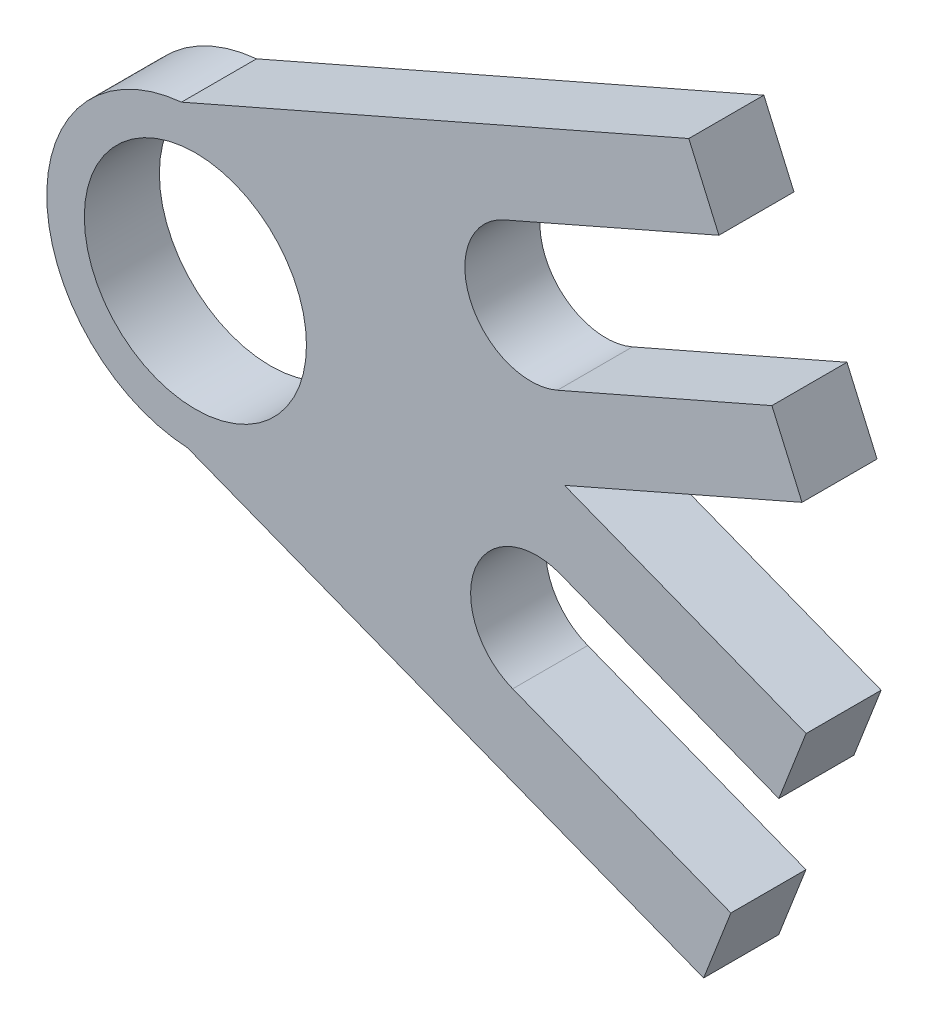
from build123d import *

# Parameters (mm, degrees)
SKETCH1_R           = 12.573
SKETCH1_R_2         = 9.398
BOSS_EXTRUDE1_DEPTH = 3.175


with BuildPart() as part:
    # Sketch1 → Boss-Extrude1 (new body, symmetric)
    with BuildSketch(Plane.XY):
        with BuildLine():
            ThreePointArc((-578.972943543, -1.57558157), (-586.333231698, 1.301508328), (-583.456141799, 8.661796483))
            Line((-583.456141799, 8.661796483), (-565.308062523, 16.6092843))
            Line((-565.308062523, 16.6092843), (-567.855334259, 22.425976375))
            Line((-567.855334259, 22.425976375), (-610.775024162, 3.630394351))
            ThreePointArc((-610.775024162, 3.630394351), (-605.901582727, 3.129161319), (-601.589679699, 0.803401606))
            Line((-601.589679699, 0.803401606), (-578.370817834, -8.244100669))
            Line((-578.370817834, -8.244100669), (-558.277592531, 0.555214171))
            Line((-558.277592531, 0.555214171), (-560.824864268, 6.371906247))
            Line((-560.824864268, 6.371906247), (-578.972943543, -1.57558157))
        make_face()
        with BuildLine():
            Line((-578.370817834, -8.244100669), (-601.589679699, 0.803401606))
            ThreePointArc((-601.589679699, 0.803401606), (-598.22471789, -3.531900701), (-597.027, -8.887578616))
            ThreePointArc((-597.027, -8.887578616), (-598.11680147, -14.007781788), (-601.197282434, -18.240367853))
            Line((-601.197282434, -18.240367853), (-578.370817834, -8.244100669))
        make_face()
        with BuildLine():
            ThreePointArc((-601.197282434, -18.240367853), (-605.409721654, -20.741771815), (-610.258379573, -21.443328906))
            Line((-610.258379573, -21.443328906), (-566.600880762, -38.454986158))
            Line((-566.600880762, -38.454986158), (-564.295375476, -32.538302511))
            Line((-564.295375476, -32.538302511), (-582.755428455, -25.34512602))
            ThreePointArc((-582.755428455, -25.34512602), (-585.933265412, -18.109599759), (-578.697739152, -14.931762801))
            Line((-578.697739152, -14.931762801), (-560.237686173, -22.124939293))
            Line((-560.237686173, -22.124939293), (-557.932180888, -16.208255646))
            Line((-557.932180888, -16.208255646), (-578.370817834, -8.244100669))
            Line((-578.370817834, -8.244100669), (-601.197282434, -18.240367853))
        make_face()
        with Locations((-609.6, -8.887578616)):
            Circle(SKETCH1_R)
        with Locations((-609.6, -8.887578616)):
            Circle(SKETCH1_R_2, mode=Mode.SUBTRACT)
    extrude(amount=BOSS_EXTRUDE1_DEPTH, both=True)


solid = part.part
